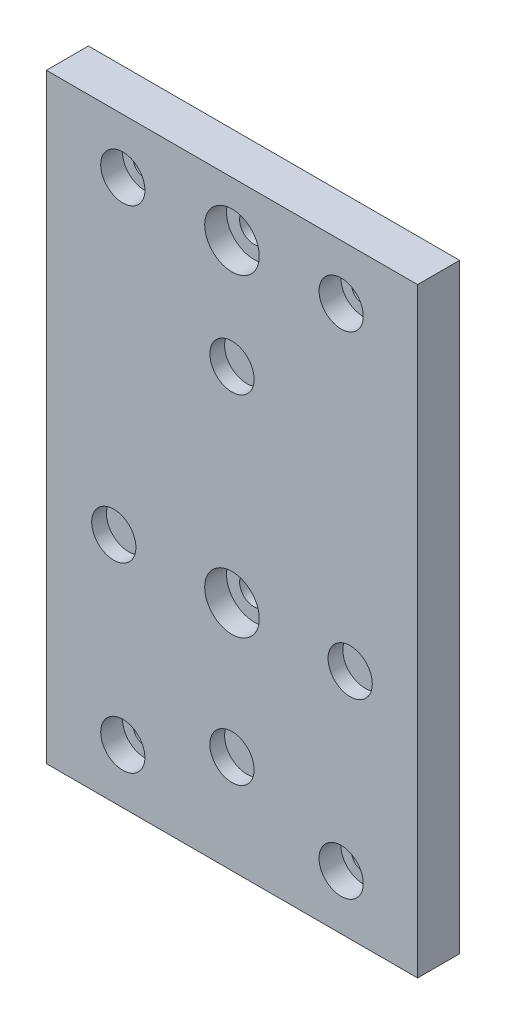
from build123d import *

# Parameters (mm, degrees)
SKETCH1_W           = 68
SKETCH1_H           = 110
SKETCH1_R           = 2.1
SKETCH1_R_2         = 4.05
SKETCH1_R_3         = 2.6
BOSS_EXTRUDE1_DEPTH = 7.7
SKETCH2_R           = 6.304633146
SKETCH2_R_2         = 7.334333348
SKETCH2_R_3         = 8.114040952
SKETCH2_R_4         = 11.073656437
BOSS_EXTRUDE2_DEPTH = 5
SKETCH3_R           = 4.05
SKETCH3_R_2         = 5
CUT_EXTRUDE1_DEPTH  = 4


with BuildPart() as part:
    # Sketch1 → Boss-Extrude1 (new body)
    with BuildSketch(Plane.XY):
        Rectangle(SKETCH1_W, SKETCH1_H)
        with Locations((20, 45)):
            Circle(SKETCH1_R, mode=Mode.SUBTRACT)
        with Locations((-20, 45)):
            Circle(SKETCH1_R, mode=Mode.SUBTRACT)
        with Locations((20, -45)):
            Circle(SKETCH1_R, mode=Mode.SUBTRACT)
        with Locations((-20, -45)):
            Circle(SKETCH1_R, mode=Mode.SUBTRACT)
        with Locations((21.650635095, -12.5)):
            Circle(SKETCH1_R_2, mode=Mode.SUBTRACT)
        with Locations((0, 25)):
            Circle(SKETCH1_R_2, mode=Mode.SUBTRACT)
        with Locations((-21.650635095, -12.5)):
            Circle(SKETCH1_R_2, mode=Mode.SUBTRACT)
        with Locations((0, -36.95)):
            Circle(SKETCH1_R_2, mode=Mode.SUBTRACT)
        with Locations((0, 45)):
            Circle(SKETCH1_R_3, mode=Mode.SUBTRACT)
        with Locations((0, -12.5)):
            Circle(SKETCH1_R_3, mode=Mode.SUBTRACT)
    extrude(amount=BOSS_EXTRUDE1_DEPTH)

    # Sketch2 → Boss-Extrude2 (add)
    with BuildSketch(Plane(origin=(0, 0, 0), x_dir=(-1, 0, 0), z_dir=(0, 0, -1))):
        with Locations((-21.650635095, -12.5)):
            Circle(SKETCH2_R)
        with Locations((0, 25)):
            Circle(SKETCH2_R_2)
        with Locations((21.650635095, -12.5)):
            Circle(SKETCH2_R_3)
        with Locations((0, -36.95)):
            Circle(SKETCH2_R_4)
    extrude(amount=-BOSS_EXTRUDE2_DEPTH)

    # Sketch3 → Cut-Extrude1 (cut)
    with BuildSketch(Plane(origin=(0, 0, 7.7), x_dir=(-1, 0, 0), z_dir=(0, 0, -1))):
        with Locations((-20, 45)):
            Circle(SKETCH3_R)
        with Locations((20, 45)):
            Circle(SKETCH3_R)
        with Locations((-20, -45)):
            Circle(SKETCH3_R)
        with Locations((20, -45)):
            Circle(SKETCH3_R)
        with Locations((0, 45)):
            Circle(SKETCH3_R_2)
        with Locations((0, -12.5)):
            Circle(SKETCH3_R_2)
    extrude(amount=CUT_EXTRUDE1_DEPTH, mode=Mode.SUBTRACT)


solid = part.part
